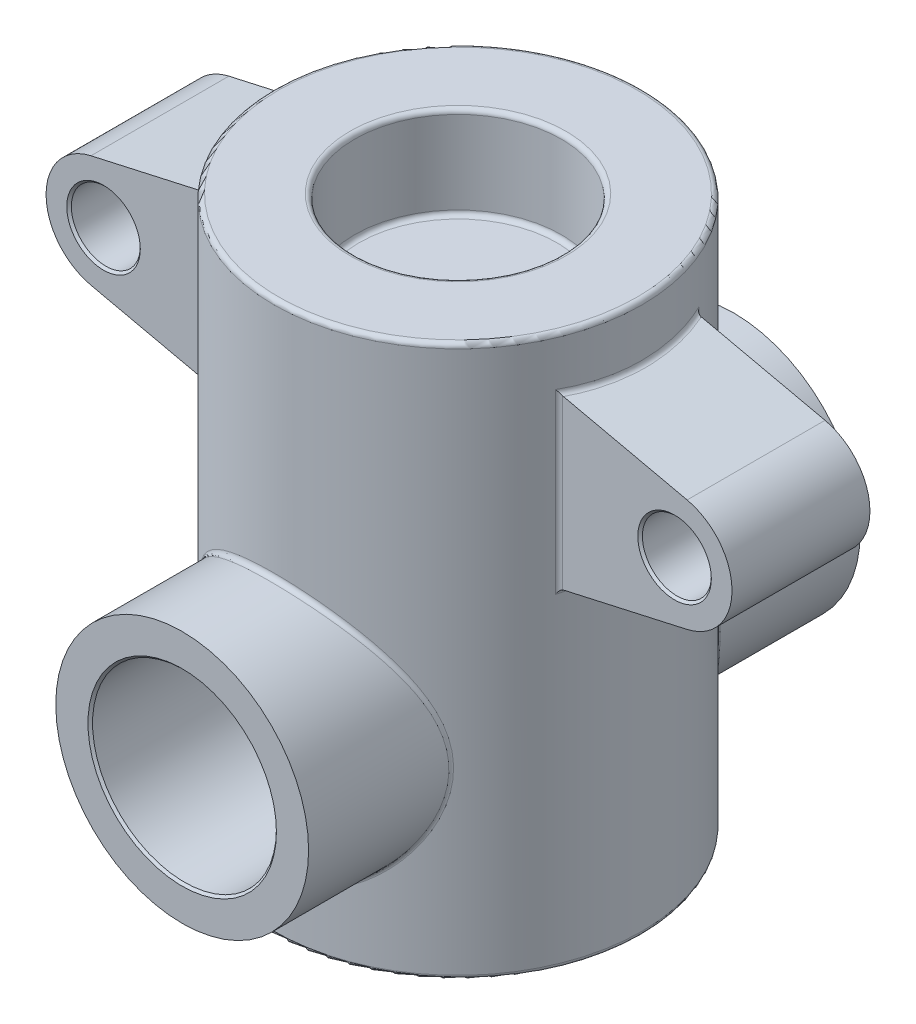
from build123d import *

# Parameters (mm, degrees)
SKETCH1_W           = 40
SKETCH1_H           = 120
SKETCH2_R           = 7.5
BOSS_EXTRUDE1_DEPTH = 15
SKETCH3_R           = 27.5
BOSS_EXTRUDE2_DEPTH = 60
SKETCH4_R           = 20
CUT_EXTRUDE1_DEPTH  = 60
SKETCH5_R           = 22.5
CUT_EXTRUDE2_DEPTH  = 20
FILLET1_R           = 1
FILLET3_R           = 1
CHAMFER1_SIZE       = 0.5


with BuildPart() as part:
    # Sketch1 → Revolve1 (revolve)
    with BuildSketch(Plane.XY):
        with Locations((20, 60)):
            Rectangle(SKETCH1_W, SKETCH1_H)
    revolve(axis=Axis((0, 0, 0), (0, 1, 0)))

    # Sketch2 → Boss-Extrude1 (add, symmetric)
    with BuildSketch(Plane.XY):
        with BuildLine():
            Line((30, 110), (30, 70))
            Line((30, 70), (64.841230381, 77.802096697))
            ThreePointArc((64.841230381, 77.802096697), (74.609718893, 90), (64.841230381, 102.197903303))
            Line((64.841230381, 102.197903303), (30, 110))
        make_face()
        with Locations((62.109718893, 90)):
            Circle(SKETCH2_R, mode=Mode.SUBTRACT)
    boss_extrude1 = extrude(amount=BOSS_EXTRUDE1_DEPTH, both=True)

    # Mirror1: Boss-Extrude1 across plane
    add(boss_extrude1.mirror(Plane(origin=(0, 0, 0), x_dir=(0, 0, 1), z_dir=(1, 0, 0))))

    # Sketch3 → Boss-Extrude2 (add, symmetric)
    with BuildSketch(Plane.XY):
        with Locations((0, 40)):
            Circle(SKETCH3_R)
    extrude(amount=BOSS_EXTRUDE2_DEPTH, both=True)

    # Sketch4 → Cut-Extrude1 (cut, symmetric)
    with BuildSketch(Plane.XY):
        with Locations((0, 40)):
            Circle(SKETCH4_R)
    extrude(amount=CUT_EXTRUDE1_DEPTH, both=True, mode=Mode.SUBTRACT)

    # Sketch5 → Cut-Extrude2 (cut)
    with BuildSketch(Plane(origin=(0, 120, 0), x_dir=(1, 0, 0), z_dir=(0, 1, 0))):
        Circle(SKETCH5_R)
    extrude(amount=-CUT_EXTRUDE2_DEPTH, mode=Mode.SUBTRACT)

    # Fillet1
    fillet1_edges = [part.edges().sort_by_distance(p)[0] for p in [
        (39.262158828, 72.074101804, -7.647410293),
        (37.080992435, 90, -15),
        (37.080992435, 90, 15),
        (39.262158828, 107.925898196, -7.647410293),
        (-37.080992435, 90, -15),
        (-40, 72.239328695, 0),
        (-40, 107.760671305, 0),
        (-37.080992435, 90, 15),
        (-40, 0, 0),
        (-40, 120, 0),
        (-27.5, 40, -29.047375097),
        (-27.5, 40, 29.047375097),
        (-22.5, 120, 0),
    ]]
    fillet(fillet1_edges, radius=FILLET1_R)

    # Fillet3
    fillet3_edges = [part.edges().sort_by_distance(p)[0] for p in [
        (-22.5, 100, 0),
    ]]
    fillet(fillet3_edges, radius=FILLET3_R)

    # Chamfer1
    chamfer1_edges = [part.edges().sort_by_distance(p)[0] for p in [
        (54.609718893, 90, -15),
        (54.609718893, 90, 15),
        (-54.609718893, 90, 15),
        (-54.609718893, 90, -15),
        (-20, 40, -60),
        (-20, 40, 60),
    ]]
    chamfer(chamfer1_edges, length=CHAMFER1_SIZE)


solid = part.part
